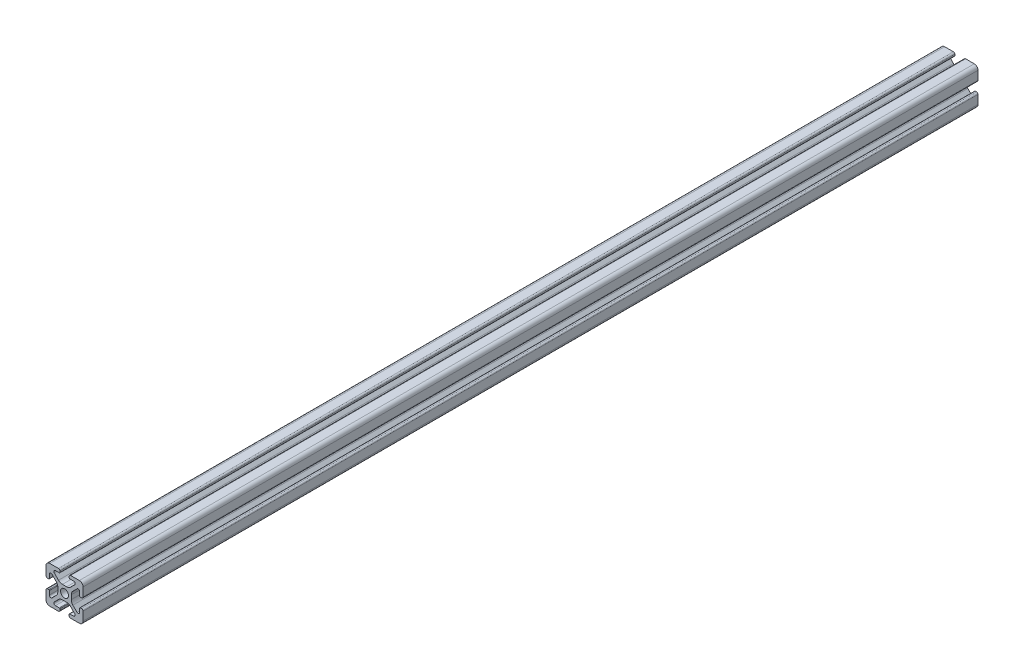
from build123d import *

# Parameters (mm, degrees)
SKETCH1_R           = 2.1463
BOSS_EXTRUDE1_DEPTH = 241.3


with BuildPart() as part:
    # Sketch1 → Boss-Extrude1 (new body, symmetric)
    with BuildSketch(Plane.XY):
        with BuildLine():
            Line((-9.9949, 7.9883), (-9.9949, 3.2893))
            ThreePointArc((-9.9949, 3.2893), (-9.76427588, 2.73252412), (-9.2075, 2.5019))
            Line((-9.2075, 2.5019), (-8.4963, 2.5019))
            ThreePointArc((-8.4963, 2.5019), (-8.280773853, 2.591173853), (-8.1915, 2.8067))
            Line((-8.1915, 2.8067), (-8.1915, 4.9149))
            ThreePointArc((-8.1915, 4.9149), (-7.674065253, 5.689295824), (-6.760603096, 5.507596904))
            Line((-6.760603096, 5.507596904), (-4.505765747, 3.252759555))
            ThreePointArc((-4.505765747, 3.252759555), (-3.856054457, 2.280397894), (-3.627906192, 1.133419111))
            Line((-3.627906192, 1.133419111), (-3.627906192, -1.133419111))
            ThreePointArc((-3.627906192, -1.133419111), (-3.856054457, -2.280397894), (-4.505765747, -3.252759555))
            Line((-4.505765747, -3.252759555), (-6.760603096, -5.507596904))
            ThreePointArc((-6.760603096, -5.507596904), (-7.674065253, -5.689295824), (-8.1915, -4.9149))
            Line((-8.1915, -4.9149), (-8.1915, -2.8067))
            ThreePointArc((-8.1915, -2.8067), (-8.280773853, -2.591173853), (-8.4963, -2.5019))
            Line((-8.4963, -2.5019), (-9.2075, -2.5019))
            ThreePointArc((-9.2075, -2.5019), (-9.76427588, -2.73252412), (-9.9949, -3.2893))
            Line((-9.9949, -3.2893), (-9.9949, -7.9883))
            ThreePointArc((-9.9949, -7.9883), (-9.407180467, -9.407180467), (-7.9883, -9.9949))
            Line((-7.9883, -9.9949), (-3.2893, -9.9949))
            ThreePointArc((-3.2893, -9.9949), (-2.73252412, -9.76427588), (-2.5019, -9.2075))
            Line((-2.5019, -9.2075), (-2.5019, -8.4963))
            ThreePointArc((-2.5019, -8.4963), (-2.591173853, -8.280773853), (-2.8067, -8.1915))
            Line((-2.8067, -8.1915), (-4.9149, -8.1915))
            ThreePointArc((-4.9149, -8.1915), (-5.689295824, -7.674065253), (-5.507596904, -6.760603096))
            Line((-5.507596904, -6.760603096), (-3.252759555, -4.505765747))
            ThreePointArc((-3.252759555, -4.505765747), (-2.280397894, -3.856054457), (-1.133419111, -3.627906192))
            Line((-1.133419111, -3.627906192), (1.133419111, -3.627906192))
            ThreePointArc((1.133419111, -3.627906192), (2.280397894, -3.856054457), (3.252759555, -4.505765747))
            Line((3.252759555, -4.505765747), (5.507596904, -6.760603096))
            ThreePointArc((5.507596904, -6.760603096), (5.689295824, -7.674065253), (4.9149, -8.1915))
            Line((4.9149, -8.1915), (2.8067, -8.1915))
            ThreePointArc((2.8067, -8.1915), (2.591173853, -8.280773853), (2.5019, -8.4963))
            Line((2.5019, -8.4963), (2.5019, -9.2075))
            ThreePointArc((2.5019, -9.2075), (2.73252412, -9.76427588), (3.2893, -9.9949))
            Line((3.2893, -9.9949), (7.9883, -9.9949))
            ThreePointArc((7.9883, -9.9949), (9.407180467, -9.407180467), (9.9949, -7.9883))
            Line((9.9949, -7.9883), (9.9949, -3.2893))
            ThreePointArc((9.9949, -3.2893), (9.76427588, -2.73252412), (9.2075, -2.5019))
            Line((9.2075, -2.5019), (8.4963, -2.5019))
            ThreePointArc((8.4963, -2.5019), (8.280773853, -2.591173853), (8.1915, -2.8067))
            Line((8.1915, -2.8067), (8.1915, -4.9149))
            ThreePointArc((8.1915, -4.9149), (7.674065253, -5.689295824), (6.760603096, -5.507596904))
            Line((6.760603096, -5.507596904), (4.505765747, -3.252759555))
            ThreePointArc((4.505765747, -3.252759555), (3.856054457, -2.280397894), (3.627906192, -1.133419111))
            Line((3.627906192, -1.133419111), (3.627906192, 1.133419111))
            ThreePointArc((3.627906192, 1.133419111), (3.856054457, 2.280397894), (4.505765747, 3.252759555))
            Line((4.505765747, 3.252759555), (6.760603096, 5.507596904))
            ThreePointArc((6.760603096, 5.507596904), (7.674065253, 5.689295824), (8.1915, 4.9149))
            Line((8.1915, 4.9149), (8.1915, 2.8067))
            ThreePointArc((8.1915, 2.8067), (8.280773853, 2.591173853), (8.4963, 2.5019))
            Line((8.4963, 2.5019), (9.2075, 2.5019))
            ThreePointArc((9.2075, 2.5019), (9.76427588, 2.73252412), (9.9949, 3.2893))
            Line((9.9949, 3.2893), (9.9949, 7.9883))
            ThreePointArc((9.9949, 7.9883), (9.407180467, 9.407180467), (7.9883, 9.9949))
            Line((7.9883, 9.9949), (3.2893, 9.9949))
            ThreePointArc((3.2893, 9.9949), (2.73252412, 9.76427588), (2.5019, 9.2075))
            Line((2.5019, 9.2075), (2.5019, 8.4963))
            ThreePointArc((2.5019, 8.4963), (2.591173853, 8.280773853), (2.8067, 8.1915))
            Line((2.8067, 8.1915), (4.9149, 8.1915))
            ThreePointArc((4.9149, 8.1915), (5.689295824, 7.674065253), (5.507596904, 6.760603096))
            Line((5.507596904, 6.760603096), (3.252759555, 4.505765747))
            ThreePointArc((3.252759555, 4.505765747), (2.280397894, 3.856054457), (1.133419111, 3.627906192))
            Line((1.133419111, 3.627906192), (-1.133419111, 3.627906192))
            ThreePointArc((-1.133419111, 3.627906192), (-2.280397894, 3.856054457), (-3.252759555, 4.505765747))
            Line((-3.252759555, 4.505765747), (-5.507596904, 6.760603096))
            ThreePointArc((-5.507596904, 6.760603096), (-5.689295824, 7.674065253), (-4.9149, 8.1915))
            Line((-4.9149, 8.1915), (-2.8067, 8.1915))
            ThreePointArc((-2.8067, 8.1915), (-2.591173853, 8.280773853), (-2.5019, 8.4963))
            Line((-2.5019, 8.4963), (-2.5019, 9.2075))
            ThreePointArc((-2.5019, 9.2075), (-2.73252412, 9.76427588), (-3.2893, 9.9949))
            Line((-3.2893, 9.9949), (-7.9883, 9.9949))
            ThreePointArc((-7.9883, 9.9949), (-9.407180467, 9.407180467), (-9.9949, 7.9883))
        make_face()
        Circle(SKETCH1_R, mode=Mode.SUBTRACT)
    extrude(amount=BOSS_EXTRUDE1_DEPTH, both=True)


solid = part.part
